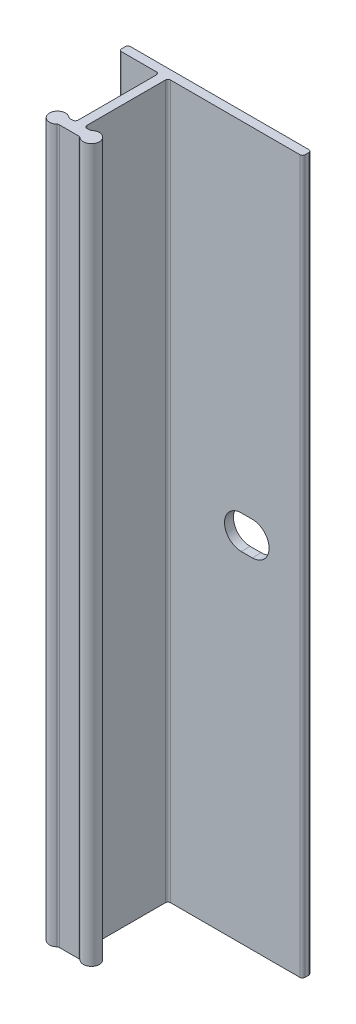
from build123d import *

# Parameters (mm, degrees)
BOSS_EXTRUDE1_DEPTH = 50.8
CUT_EXTRUDE1_DEPTH  = 2.27


with BuildPart() as part:
    # Sketch2 → Boss-Extrude1 (new body, symmetric)
    with BuildSketch(Plane(origin=(0, 0, 0), x_dir=(1, 0, 0), z_dir=(0, 1, 0))):
        with BuildLine():
            Line((-5.969, 0), (19.431, 0))
            ThreePointArc((19.431, 0), (19.700407684, -0.111592316), (19.812, -0.381))
            Line((19.812, -0.381), (19.812, -0.889))
            ThreePointArc((19.812, -0.889), (19.700407684, -1.158407684), (19.431, -1.27))
            Line((19.431, -1.27), (1.016, -1.27))
            ThreePointArc((1.016, -1.27), (0.746592316, -1.381592316), (0.635, -1.651))
            Line((0.635, -1.651), (0.635, -12.827))
            ThreePointArc((0.635, -12.827), (0.746592316, -13.096407684), (1.016, -13.208))
            Line((1.016, -13.208), (1.40496875, -13.208))
            ThreePointArc((1.40496875, -13.208), (1.539672592, -13.183392866), (1.656976563, -13.11275))
            ThreePointArc((1.656976563, -13.11275), (3.556, -13.97), (1.656976563, -14.82725))
            ThreePointArc((1.656976563, -14.82725), (1.539672592, -14.756607134), (1.40496875, -14.732))
            Line((1.40496875, -14.732), (-1.40496875, -14.732))
            ThreePointArc((-1.40496875, -14.732), (-1.539672592, -14.756607134), (-1.656976563, -14.82725))
            ThreePointArc((-1.656976563, -14.82725), (-3.556, -13.97), (-1.656976563, -13.11275))
            ThreePointArc((-1.656976563, -13.11275), (-1.539672592, -13.183392866), (-1.40496875, -13.208))
            Line((-1.40496875, -13.208), (-1.016, -13.208))
            ThreePointArc((-1.016, -13.208), (-0.746592316, -13.096407684), (-0.635, -12.827))
            Line((-0.635, -12.827), (-0.635, -1.651))
            ThreePointArc((-0.635, -1.651), (-0.746592316, -1.381592316), (-1.016, -1.27))
            Line((-1.016, -1.27), (-5.969, -1.27))
            ThreePointArc((-5.969, -1.27), (-6.238407684, -1.158407684), (-6.35, -0.889))
            Line((-6.35, -0.889), (-6.35, -0.381))
            ThreePointArc((-6.35, -0.381), (-6.238407684, -0.111592316), (-5.969, 0))
        make_face()
    extrude(amount=BOSS_EXTRUDE1_DEPTH, both=True)

    # Sketch3 → Cut-Extrude1 (cut, through all)
    with BuildSketch(Plane.XY.offset(1.27)):
        with BuildLine():
            Line((11.08075, 2.38125), (12.66825, 2.38125))
            ThreePointArc((12.66825, 2.38125), (15.0495, 0), (12.66825, -2.38125))
            Line((12.66825, -2.38125), (11.08075, -2.38125))
            ThreePointArc((11.08075, -2.38125), (8.6995, 0), (11.08075, 2.38125))
        make_face()
    extrude(amount=-CUT_EXTRUDE1_DEPTH, mode=Mode.SUBTRACT)


solid = part.part
